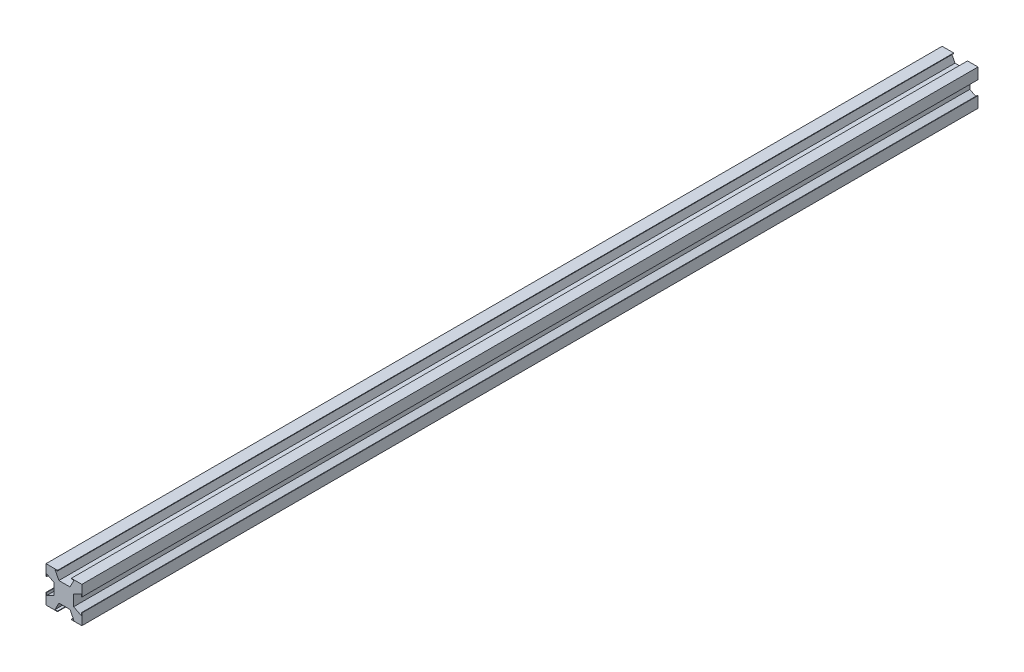
from build123d import *

# Parameters (mm, degrees)
Y_KSEKLIK_EKSTR_ZYON1_DEPTH = 500
Y_KSEKLIK_EKSTR_ZYON3_DEPTH = 500


with BuildPart() as part:
    # Çizim1 → Yükseklik-Ekstrüzyon1 (new body)
    with BuildSketch(Plane.XY):
        Polygon((-5.15760167, 10), (-2.80302277, 5.444963707), (3.391667495, 5.444963707), (5.746246396, 10), (10, 10), (10, 5.45), (5.445076204, 3.095), (5.445076204, -3.095), (10, -5.45), (10, -10), (5.746246396, -10), (3.391667495, -5.444963707), (-2.80302277, -5.444963707), (-5.15760167, -10), (-10, -10), (-10, -5.45), (-5.445076204, -3.095), (-5.445076204, 3.095), (-10, 5.45), (-10, 10), align=None)
    extrude(amount=Y_KSEKLIK_EKSTR_ZYON1_DEPTH)

    # Çizim4 → Yükseklik-Ekstrüzyon3 (add)
    with BuildSketch(Plane.XY.offset(500)):
        Polygon((-5.15760167, 10), (-3.54995598, 10), (-3.54995598, 9.705121592), (-5.005173801, 9.705121592), align=None)
        Polygon((10, 3.84), (9.71, 3.84), (9.71, 5.300063353), (10, 5.45), align=None)
        Polygon((5.593818526, 9.705121592), (5.746246396, 10), (4.138600705, 10), (4.138600705, 9.705121592), align=None)
        Polygon((5.746246396, -10), (4.138600705, -10), (4.138600705, -9.705121592), (5.593818526, -9.705121592), align=None)
        Polygon((-5.005173801, -9.705121592), (-5.15760167, -10), (-3.54995598, -10), (-3.54995598, -9.705121592), align=None)
        Polygon((-10, 5.45), (-10, 3.84), (-9.71, 3.84), (-9.71, 5.300063353), align=None)
        Polygon((9.71, -5.300063353), (10, -5.45), (10, -3.84), (9.71, -3.84), align=None)
        Polygon((-9.71, -5.300063353), (-10, -5.45), (-10, -3.84), (-9.71, -3.84), align=None)
    extrude(amount=-Y_KSEKLIK_EKSTR_ZYON3_DEPTH)


solid = part.part
